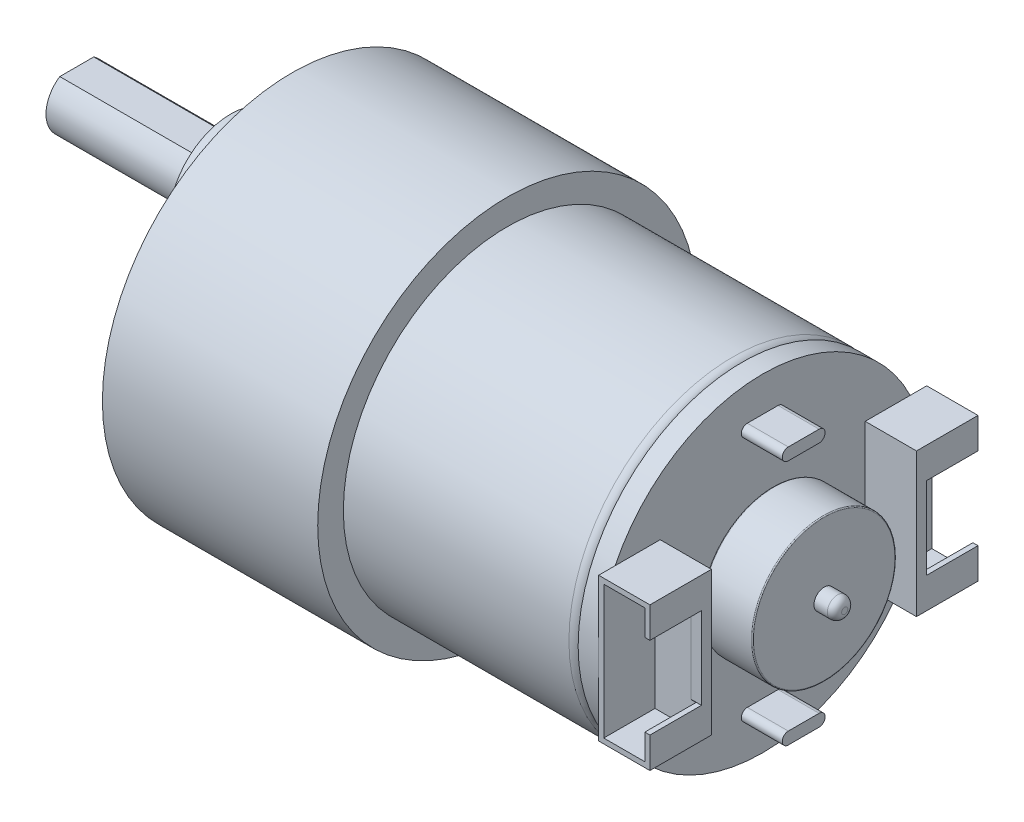
from build123d import *

# Parameters (mm, degrees)
SKETCH2_R           = 6
BOSS_EXTRUDE1_DEPTH = 6
SKETCH3_R           = 3
BOSS_EXTRUDE2_DEPTH = 15
CUT_EXTRUDE1_DEPTH  = 13
CUT_EXTRUDE2_DEPTH  = 0.5
SKETCH6_R           = 1.5
CUT_EXTRUDE3_DEPTH  = 2
CIRPATTERN1_COUNT   = 6
BOSS_EXTRUDE3_DEPTH = 6
SKETCH8_R           = 16
BOSS_EXTRUDE4_DEPTH = 2
SKETCH9_R           = 7
BOSS_EXTRUDE5_DEPTH = 6
SKETCH10_R          = 7
SKETCH10_R_2        = 1
CUT_EXTRUDE4_DEPTH  = 1
FILLET2_R           = 0.1
FILLET3_R           = 0.1
SKETCH11_W          = 6
SKETCH11_H          = 14
BOSS_EXTRUDE6_DEPTH = 5
SKETCH13_W          = 4
SKETCH13_H          = 13
CUT_EXTRUDE6_DEPTH  = 5
SKETCH14_W          = 5.026606417
SKETCH14_H          = 8
CUT_EXTRUDE7_DEPTH  = 1


with BuildPart() as part:
    # Sketch1 → Revolve1 (revolve)
    with BuildSketch(Plane(origin=(0, 0, 0), x_dir=(1, 0, 0), z_dir=(0, 1, 0))):
        with BuildLine():
            Line((0, 18.5), (-21, 18.5))
            Line((-21, 18.5), (-21, 0))
            Line((-21, 0), (32.9, 0))
            Line((32.9, 0), (32.9, 0.3))
            ThreePointArc((32.9, 0.3), (32.694974747, 0.794974747), (32.2, 1))
            Line((32.2, 1), (22.9, 1))
            Line((22.9, 1), (22.9, 15.1))
            ThreePointArc((22.9, 15.1), (22.636396103, 15.736396103), (22, 16))
            Line((22, 16), (0, 16))
            Line((0, 16), (0, 18.5))
        make_face()
    revolve(axis=Axis((-21, 0, 0), (1, 0, 0)))

    # Sketch2 → Boss-Extrude1 (add)
    with BuildSketch(Plane.ZY.offset(21)):
        with Locations((0, 6)):
            Circle(SKETCH2_R)
    extrude(amount=BOSS_EXTRUDE1_DEPTH)

    # Sketch3 → Boss-Extrude2 (add)
    with BuildSketch(Plane.ZY.offset(27)):
        with Locations((0, 6)):
            Circle(SKETCH3_R)
    extrude(amount=BOSS_EXTRUDE2_DEPTH)

    # Sketch4 → Cut-Extrude1 (cut)
    with BuildSketch(Plane.ZY.offset(42)):
        with BuildLine():
            Line((-1.658312395, 8.5), (1.658312395, 8.5))
            ThreePointArc((1.658312395, 8.5), (0, 9), (-1.658312395, 8.5))
        make_face()
    extrude(amount=-CUT_EXTRUDE1_DEPTH, mode=Mode.SUBTRACT)

    # Sketch5 → Cut-Extrude2 (cut)
    with BuildSketch(Plane.ZY.offset(21)):
        with BuildLine():
            ThreePointArc((-4.982608643, 10.916666667), (0, -1), (4.982608643, 10.916666667))
            ThreePointArc((4.982608643, 10.916666667), (0, -12), (-4.982608643, 10.916666667))
        make_face()
    extrude(amount=-CUT_EXTRUDE2_DEPTH, mode=Mode.SUBTRACT)

    # Sketch6 → Cut-Extrude3 (cut)
    with BuildSketch(Plane.ZY.offset(21)):
        with Locations((15, 0)):
            Circle(SKETCH6_R)
    cut_extrude3 = extrude(amount=-CUT_EXTRUDE3_DEPTH, mode=Mode.SUBTRACT)

    # CirPattern1: Cut-Extrude3 ×6 about axis
    cirpattern1_axis = Axis((0, 0, 0), (1, 0, 0))
    for i in range(1, CIRPATTERN1_COUNT):
        add(cut_extrude3.rotate(cirpattern1_axis, i * 360 / CIRPATTERN1_COUNT), mode=Mode.SUBTRACT)

    # Sketch7 → Boss-Extrude3 (add)
    with BuildSketch(Plane(origin=(22.9, 0, 0), x_dir=(0, 0, -1), z_dir=(1, 0, 0))):
        with BuildLine():
            Line((1.5, 11.410824506), (-1.5, 11.410824506))
            ThreePointArc((-1.5, 11.410824506), (-2.089175494, 12), (-1.5, 12.589175494))
            Line((-1.5, 12.589175494), (1.5, 12.589175494))
            ThreePointArc((1.5, 12.589175494), (2.089175494, 12), (1.5, 11.410824506))
        make_face()
        with BuildLine():
            Line((1.5, -11.410824506), (-1.5, -11.410824506))
            ThreePointArc((-1.5, -11.410824506), (-2.089175494, -12), (-1.5, -12.589175494))
            Line((-1.5, -12.589175494), (1.5, -12.589175494))
            ThreePointArc((1.5, -12.589175494), (2.089175494, -12), (1.5, -11.410824506))
        make_face()
    extrude(amount=BOSS_EXTRUDE3_DEPTH)

    # Sketch8 → Boss-Extrude4 (add)
    with BuildSketch(Plane(origin=(22.9, 0, 0), x_dir=(0, 0, -1), z_dir=(1, 0, 0))):
        Circle(SKETCH8_R)
    extrude(amount=BOSS_EXTRUDE4_DEPTH)

    # Sketch9 → Boss-Extrude5 (add)
    with BuildSketch(Plane(origin=(24.9, 0, 0), x_dir=(0, 0, -1), z_dir=(1, 0, 0))):
        Circle(SKETCH9_R)
    extrude(amount=BOSS_EXTRUDE5_DEPTH)

    # Sketch10 → Cut-Extrude4 (cut)
    with BuildSketch(Plane(origin=(24.9, 0, 0), x_dir=(0, 0, -1), z_dir=(1, 0, 0))):
        Circle(SKETCH10_R)
        Circle(SKETCH10_R_2, mode=Mode.SUBTRACT)
    extrude(amount=CUT_EXTRUDE4_DEPTH, mode=Mode.SUBTRACT)

    # Fillet2
    fillet2_edges = [part.edges().sort_by_distance(p)[0] for p in [
        (30.9, 0, 7),
    ]]
    fillet(fillet2_edges, radius=FILLET2_R)

    # Fillet3
    fillet3_edges = [part.edges().sort_by_distance(p)[0] for p in [
        (25.9, 0, 7),
    ]]
    fillet(fillet3_edges, radius=FILLET3_R)

    # Sketch11 → Boss-Extrude6 (add)
    with BuildSketch(Plane(origin=(24.9, 0, 0), x_dir=(0, 0, -1), z_dir=(1, 0, 0))):
        with Locations((13, 0)):
            Rectangle(SKETCH11_W, SKETCH11_H)
    boss_extrude6 = extrude(amount=BOSS_EXTRUDE6_DEPTH)

    # Sketch13 → Cut-Extrude6 (cut)
    with BuildSketch(Plane(origin=(0, 0, -16), x_dir=(-1, 0, 0), z_dir=(0, 0, -1))):
        with Locations((-27.4, 0)):
            Rectangle(SKETCH13_W, SKETCH13_H)
    cut_extrude6 = extrude(amount=-CUT_EXTRUDE6_DEPTH, mode=Mode.SUBTRACT)

    # Sketch14 → Cut-Extrude7 (cut)
    with BuildSketch(Plane(origin=(29.9, 0, 0), x_dir=(0, 0, -1), z_dir=(1, 0, 0))):
        with Locations((13.486696792, 0)):
            Rectangle(SKETCH14_W, SKETCH14_H)
    cut_extrude7 = extrude(amount=-CUT_EXTRUDE7_DEPTH, mode=Mode.SUBTRACT)

    # Mirror1: Boss-Extrude6, Cut-Extrude6, Cut-Extrude7 across plane
    add(boss_extrude6.mirror(Plane.XY))
    add(cut_extrude6.mirror(Plane.XY), mode=Mode.SUBTRACT)
    add(cut_extrude7.mirror(Plane.XY), mode=Mode.SUBTRACT)


solid = part.part
